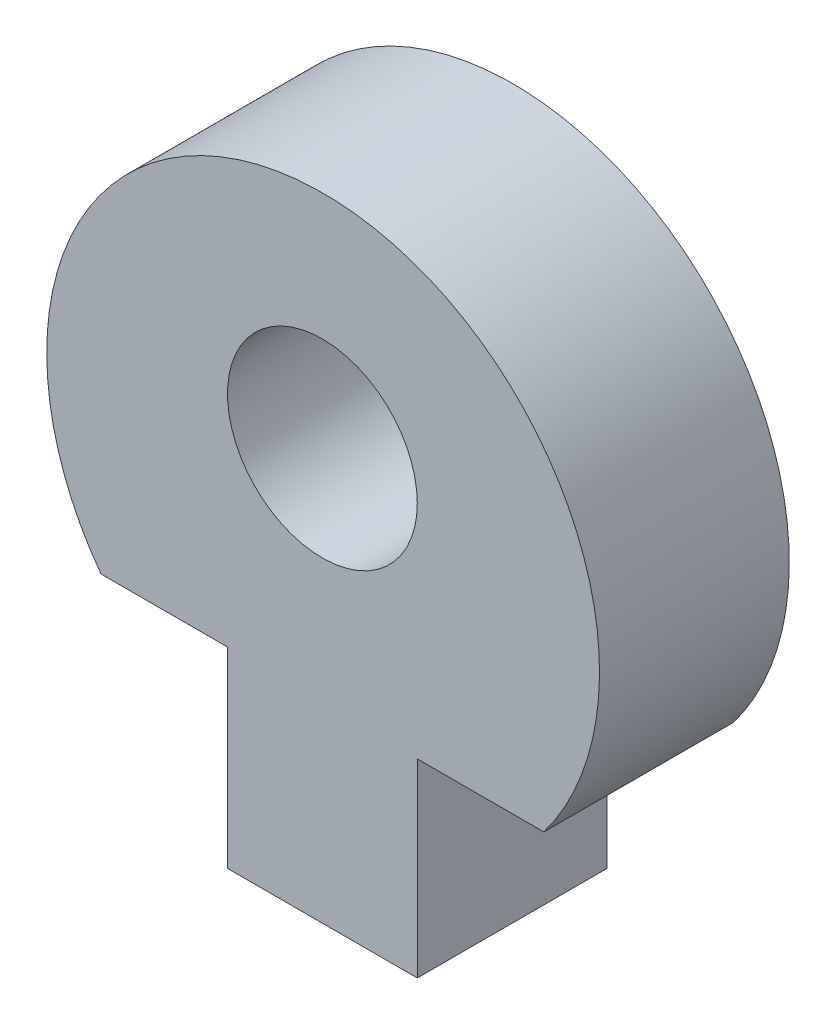
from build123d import *

# Parameters (mm, degrees)
MODEL_R             = 3
BOSS_EXTRUDE1_DEPTH = 6


with BuildPart() as part:
    # Model → Boss-Extrude1 (new body)
    with BuildSketch(Plane.XY):
        with BuildLine():
            Line((55.946512191, 18.417561913), (55.946512191, 12.417561913))
            Line((55.946512191, 12.417561913), (49.946512191, 12.417561913))
            Line((49.946512191, 12.417561913), (49.946512191, 18.479362937))
            Line((49.946512191, 18.479362937), (45.946512191, 18.479362937))
            ThreePointArc((45.946512191, 18.479362937), (53.008176567, 32.417507278), (59.946512191, 18.417561913))
            Line((59.946512191, 18.417561913), (55.946512191, 18.417561913))
        make_face()
        with Locations((52.946512191, 25.417561913)):
            Circle(MODEL_R, mode=Mode.SUBTRACT)
    extrude(amount=BOSS_EXTRUDE1_DEPTH)


solid = part.part
